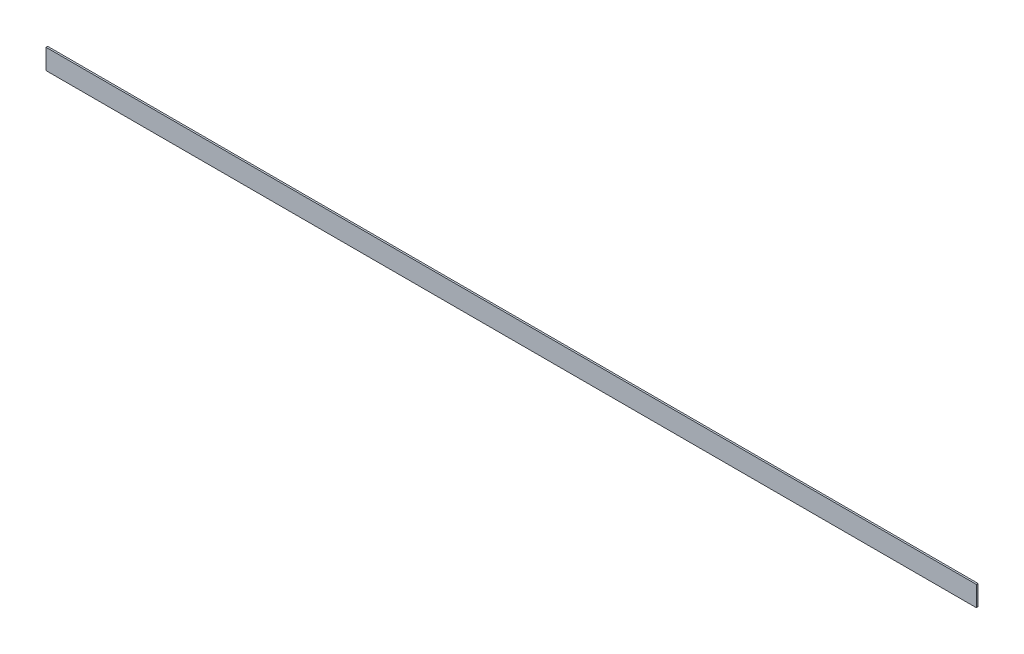
from build123d import *

# Parameters (mm, degrees)
SKETCH1_W           = 6.35
SKETCH1_H           = 76.2
BOSS_EXTRUDE1_DEPTH = 3505.2


with BuildPart() as part:
    # Sketch1 → Boss-Extrude1 (new body)
    with BuildSketch(Plane(origin=(0, 0, 0), x_dir=(0, 0, -1), z_dir=(1, 0, 0))):
        Rectangle(SKETCH1_W, SKETCH1_H)
    extrude(amount=BOSS_EXTRUDE1_DEPTH)


solid = part.part
